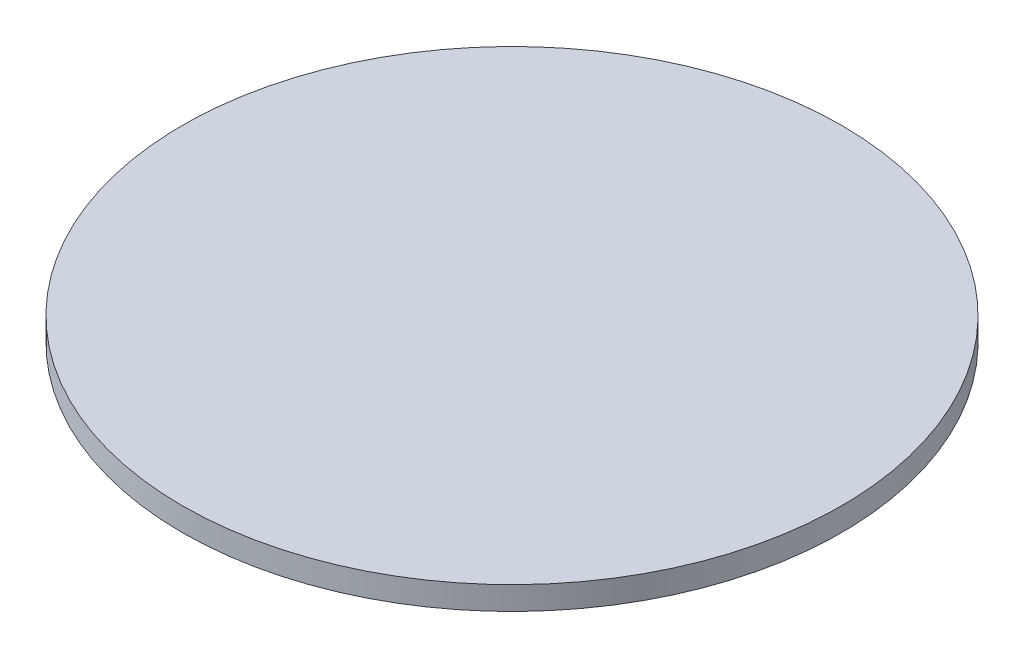
from build123d import *

# Parameters (mm, degrees)
SKETCH1_R           = 45
BOSS_EXTRUDE1_DEPTH = 3.175


with BuildPart() as part:
    # Sketch1 → Boss-Extrude1 (new body)
    with BuildSketch(Plane(origin=(0, 0, 0), x_dir=(1, 0, 0), z_dir=(0, 1, 0))):
        Circle(SKETCH1_R)
    extrude(amount=BOSS_EXTRUDE1_DEPTH)


solid = part.part
